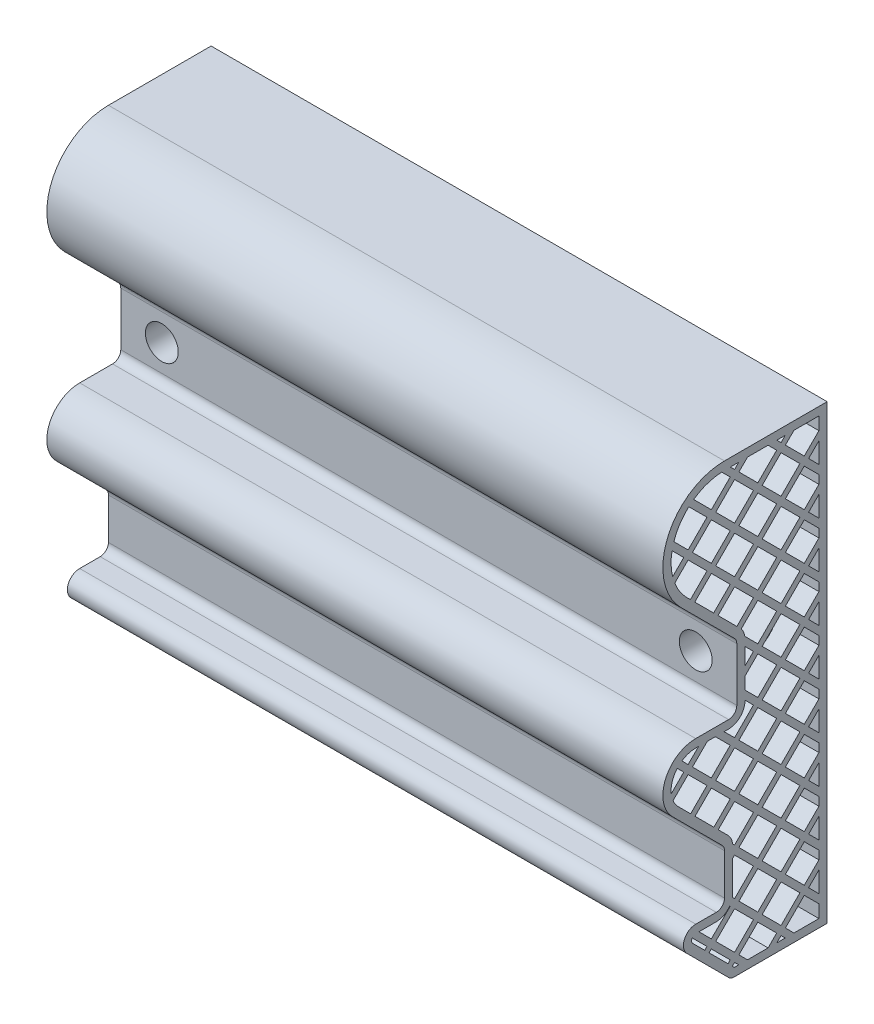
from build123d import *

# Parameters (mm, degrees)
SALIENTE_EXTRUIR1_DEPTH = 150
CORTAR_EXTRUIR3_DEPTH   = 1
CORTAR_EXTRUIR4_DEPTH   = 150
CROQUIS2_R              = 4
CORTAR_EXTRUIR1_DEPTH   = 23
CROQUIS7_R              = 5.5
CROQUIS7_R_2            = 4
SALIENTE_EXTRUIR2_DEPTH = 22
SALIENTE_EXTRUIR4_DEPTH = 1
CORTAR_EXTRUIR9_DEPTH   = 1


with BuildPart() as part:
    # Croquis1 → Saliente-Extruir1 (new body)
    with BuildSketch(Plane(origin=(0, 0, 0), x_dir=(0, 0, -1), z_dir=(1, 0, 0))):
        with BuildLine():
            Line((0, 0), (-22.597979746, 0))
            ThreePointArc((-22.597979746, 0), (-23.363346611, 0.152240935), (-24.012193309, 0.585786438))
            Line((-24.012193309, 0.585786438), (-34.121320344, 10.694913472))
            ThreePointArc((-34.121320344, 10.694913472), (-34.771638598, 13.964284113), (-32, 15.816233816))
            Line((-32, 15.816233816), (-27, 15.816233816))
            ThreePointArc((-27, 15.816233816), (-25.585786438, 16.402020254), (-25, 17.816233816))
            Line((-25, 17.816233816), (-25, 27.816233816))
            ThreePointArc((-25, 27.816233816), (-25.152240935, 28.581600681), (-25.585786438, 29.230447378))
            Line((-25.585786438, 29.230447378), (-37.656854249, 41.30151519))
            ThreePointArc((-37.656854249, 41.30151519), (-39.39103626, 50.019836899), (-32, 54.95836944))
            Line((-32, 54.95836944), (-24, 54.95836944))
            ThreePointArc((-24, 54.95836944), (-22.585786438, 55.544155877), (-22, 56.95836944))
            Line((-22, 56.95836944), (-22, 69.95836944))
            ThreePointArc((-22, 69.95836944), (-22.152240935, 70.723736304), (-22.585786438, 71.372583002))
            Line((-22.585786438, 71.372583002), (-35.606601718, 84.393398282))
            ThreePointArc((-35.606601718, 84.393398282), (-38.858192988, 100.740251485), (-25, 110))
            Line((-25, 110), (0, 110))
            Line((0, 110), (0, 0))
        make_face()
    extrude(amount=SALIENTE_EXTRUIR1_DEPTH)

    # Croquis3 → Cortar-Extruir3 (cut)
    with BuildSketch(Plane(origin=(150, 0, 0), x_dir=(0, 0, -1), z_dir=(1, 0, 0))):
        with BuildLine():
            Line((-24, 52.95836944), (-32, 52.95836944))
            ThreePointArc((-32, 52.95836944), (-37.543277195, 49.254470034), (-36.242640687, 42.715728753))
            Line((-36.242640687, 42.715728753), (-24.171572875, 30.644660941))
            ThreePointArc((-24.171572875, 30.644660941), (-23.30448187, 29.346967545), (-23, 27.816233816))
            Line((-23, 27.816233816), (-23, 17.816233816))
            ThreePointArc((-23, 17.816233816), (-24.171572875, 14.987806691), (-27, 13.816233816))
            Line((-27, 13.816233816), (-32, 13.816233816))
            ThreePointArc((-32, 13.816233816), (-32.923879533, 13.198917248), (-32.707106781, 12.109127035))
            Line((-32.707106781, 12.109127035), (-22.597979746, 2))
            Line((-22.597979746, 2), (-2, 2))
            Line((-2, 2), (-2, 108))
            Line((-2, 108), (-25, 108))
            ThreePointArc((-25, 108), (-37.010433923, 99.974884621), (-34.192388155, 85.807611845))
            Line((-34.192388155, 85.807611845), (-21.171572875, 72.786796564))
            ThreePointArc((-21.171572875, 72.786796564), (-20.30448187, 71.489103169), (-20, 69.95836944))
            Line((-20, 69.95836944), (-20, 56.95836944))
            ThreePointArc((-20, 56.95836944), (-21.171572875, 54.129942315), (-24, 52.95836944))
        make_face()
    extrude(amount=-CORTAR_EXTRUIR3_DEPTH, mode=Mode.SUBTRACT)

    # Croquis6 → Cortar-Extruir4 (cut)
    with BuildSketch(Plane(origin=(150, 0, 0), x_dir=(0, 0, -1), z_dir=(1, 0, 0))):
        Polygon((-22.539105243, 106.972348417), (-21.511453661, 108), (-23.566756826, 108), align=None)
        with BuildLine():
            Line((-25.670761009, 107.982683839), (-23.599765415, 105.911688245))
            Line((-23.599765415, 105.911688245), (-28.195959493, 101.315494168))
            Line((-28.195959493, 101.315494168), (-32.499323448, 105.618858123))
            ThreePointArc((-32.499323448, 105.618858123), (-29.252586038, 107.284767478), (-25.670761009, 107.982683839))
        make_face()
        Polygon((-22.597979746, 2), (-21.511453661, 2), (-22.539105243, 3.027651583), (-23.082368286, 2.48438854), align=None)
        Polygon((-2, 2), (-2, 5.115963337), (-5.568542495, 8.684505832), (-10.164736573, 4.088311755), (-8.076424818, 2), align=None)
        Polygon((-2, 108), (-8.076424818, 108), (-10.164736573, 105.911688245), (-5.568542495, 101.315494168), (-2, 104.884036663), align=None)
        with BuildLine():
            Line((-34.192388155, 85.807611845), (-33.291260736, 84.906484425))
            Line((-33.291260736, 84.906484425), (-29.256619665, 88.941125497))
            Line((-29.256619665, 88.941125497), (-33.852813742, 93.537319575))
            Line((-33.852813742, 93.537319575), (-37.112101908, 90.278031409))
            ThreePointArc((-37.112101908, 90.278031409), (-35.884231116, 87.891307222), (-34.192388155, 85.807611845))
        make_face()
        Polygon((-20, 68.370797333), (-20, 64.256619665), (-17.942911166, 66.313708499), align=None)
        with BuildLine():
            Line((-24, 52.95836944), (-25.093668761, 52.95836944))
            Line((-25.093668761, 52.95836944), (-22.539105243, 50.403805922))
            Line((-22.539105243, 50.403805922), (-17.942911166, 55))
            Line((-17.942911166, 55), (-20, 57.057088834))
            Line((-20, 57.057088834), (-20, 56.95836944))
            ThreePointArc((-20, 56.95836944), (-21.171572875, 54.129942315), (-24, 52.95836944))
        make_face()
        with BuildLine():
            Line((-36.242640687, 42.715728753), (-33.23491155, 39.707999616))
            Line((-33.23491155, 39.707999616), (-29.256619665, 43.686291501))
            Line((-29.256619665, 43.686291501), (-33.852813742, 48.282485579))
            Line((-33.852813742, 48.282485579), (-37.522518719, 44.612780602))
            ThreePointArc((-37.522518719, 44.612780602), (-36.97386027, 43.602670703), (-36.242640687, 42.715728753))
        make_face()
        with BuildLine():
            Line((-23, 25.194173824), (-23, 17.816233816))
            ThreePointArc((-23, 17.816233816), (-23.020762528, 17.409209069), (-23.082834572, 17.006409754))
            Line((-23.082834572, 17.006409754), (-22.539105243, 16.462680425))
            Line((-22.539105243, 16.462680425), (-17.942911166, 21.058874503))
            Line((-17.942911166, 21.058874503), (-22.539105243, 25.655068581))
            Line((-22.539105243, 25.655068581), (-23, 25.194173824))
        make_face()
        with BuildLine():
            Line((-27, 13.816233816), (-31.206367133, 13.816233816))
            Line((-31.206367133, 13.816233816), (-28.195959493, 10.805826176))
            Line((-28.195959493, 10.805826176), (-23.599765415, 15.402020254))
            Line((-23.599765415, 15.402020254), (-23.721861011, 15.52411585))
            ThreePointArc((-23.721861011, 15.52411585), (-25.151821419, 14.268807152), (-27, 13.816233816))
        make_face()
        with BuildLine():
            Line((-32.707106781, 12.109127035), (-29.799882708, 9.201902961))
            Line((-29.799882708, 9.201902961), (-29.256619665, 9.745166004))
            Line((-29.256619665, 9.745166004), (-32.851706537, 13.340252876))
            ThreePointArc((-32.851706537, 13.340252876), (-32.99317292, 12.699582409), (-32.707106781, 12.109127035))
        make_face()
        with BuildLine():
            Line((-37.622305649, 91.889148011), (-34.913473914, 94.597979746))
            Line((-34.913473914, 94.597979746), (-37.766797289, 97.451303121))
            ThreePointArc((-37.766797289, 97.451303121), (-37.995615775, 94.662404627), (-37.622305649, 91.889148011))
        make_face()
        with BuildLine():
            Line((-37.325931232, 99.131757407), (-33.852813742, 95.658639918))
            Line((-33.852813742, 95.658639918), (-29.256619665, 100.254833996))
            Line((-29.256619665, 100.254833996), (-33.679721302, 104.677935633))
            ThreePointArc((-33.679721302, 104.677935633), (-35.862752083, 102.14147164), (-37.325931232, 99.131757407))
        make_face()
        Polygon((-11.225396744, 106.972348417), (-10.197745162, 108), (-12.253048327, 108), align=None)
        Polygon((-4.507882323, 100.254833996), (-2, 97.746951673), (-2, 102.762716319), align=None)
        Polygon((-14.374368671, 108), (-12.286056916, 105.911688245), (-16.882250994, 101.315494168), (-21.478445072, 105.911688245), (-19.390133317, 108), align=None)
        Polygon((-27.578057301, 34.051145366), (-23.599765415, 38.029437252), (-28.195959493, 42.625631329), (-32.174251378, 38.647339444), align=None)
        with BuildLine():
            Line((-37.96305573, 46.293563935), (-34.913473914, 49.343145751))
            Line((-34.913473914, 49.343145751), (-36.498746009, 50.928417846))
            ThreePointArc((-36.498746009, 50.928417846), (-37.721257869, 48.765911527), (-37.96305573, 46.293563935))
        make_face()
        with BuildLine():
            Line((-35.370928508, 51.921920688), (-33.852813742, 50.403805922))
            Line((-33.852813742, 50.403805922), (-31.298250225, 52.95836944))
            Line((-31.298250225, 52.95836944), (-32, 52.95836944))
            ThreePointArc((-32, 52.95836944), (-33.763333847, 52.693406819), (-35.370928508, 51.921920688))
        make_face()
        Polygon((-32.792153571, 49.343145751), (-28.195959493, 44.746951673), (-23.599765415, 49.343145751), (-27.214989104, 52.95836944), (-29.176929881, 52.95836944), align=None)
        Polygon((-20, 59.178409178), (-16.882250994, 56.060660172), (-12.286056916, 60.656854249), (-16.882250994, 65.253048327), (-20, 62.135299321), align=None)
        with BuildLine():
            Line((-16.882250994, 67.374368671), (-12.286056916, 71.970562748))
            Line((-12.286056916, 71.970562748), (-16.882250994, 76.566756826))
            Line((-16.882250994, 76.566756826), (-20.928381547, 72.520626273))
            ThreePointArc((-20.928381547, 72.520626273), (-20.347292714, 71.588623861), (-20.04159352, 70.533711197))
            Line((-20.04159352, 70.533711197), (-16.882250994, 67.374368671))
        make_face()
        Polygon((-21.977552237, 73.592775926), (-17.942911166, 77.627416998), (-22.539105243, 82.223611076), (-26.573746315, 78.188970004), align=None)
        Polygon((-27.634406487, 79.249630176), (-23.599765415, 83.284271247), (-28.195959493, 87.880465325), (-32.230600564, 83.845824254), align=None)
        Polygon((-4.507882323, 77.627416998), (-2, 80.135299321), (-2, 75.119534675), align=None)
        Polygon((-5.568542495, 76.566756826), (-2, 72.998214331), (-2, 70.942911166), (-5.568542495, 67.374368671), (-10.164736573, 71.970562748), align=None)
        Polygon((-4.507882323, 66.313708499), (-2, 68.821590822), (-2, 63.805826176), align=None)
        Polygon((-5.568542495, 65.253048327), (-2, 61.684505832), (-2, 59.629202667), (-5.568542495, 56.060660172), (-10.164736573, 60.656854249), align=None)
        Polygon((-4.507882323, 55), (-2, 57.507882323), (-2, 52.492117677), align=None)
        Polygon((-5.568542495, 53.939339828), (-2, 50.370797333), (-2, 48.315494168), (-5.568542495, 44.746951673), (-10.164736573, 49.343145751), align=None)
        Polygon((-4.507882323, 43.686291501), (-2, 46.194173824), (-2, 41.178409178), align=None)
        Polygon((-5.568542495, 42.625631329), (-2, 39.057088834), (-2, 37.001785669), (-5.568542495, 33.433243174), (-10.164736573, 38.029437252), align=None)
        Polygon((-4.507882323, 32.372583002), (-2, 34.880465325), (-2, 29.864700679), align=None)
        Polygon((-5.568542495, 31.31192283), (-2, 27.743380335), (-2, 25.68807717), (-5.568542495, 22.119534675), (-10.164736573, 26.715728753), align=None)
        Polygon((-4.507882323, 21.058874503), (-2, 23.566756826), (-2, 18.55099218), align=None)
        Polygon((-5.568542495, 19.998214331), (-2, 16.429671836), (-2, 14.374368671), (-5.568542495, 10.805826176), (-10.164736573, 15.402020254), align=None)
        Polygon((-4.507882323, 9.745166004), (-2, 12.253048327), (-2, 7.237283681), align=None)
        Polygon((-11.225396744, 3.027651583), (-10.197745162, 2), (-12.253048327, 2), align=None)
        Polygon((-14.374368671, 2), (-12.286056916, 4.088311755), (-16.882250994, 8.684505832), (-21.478445072, 4.088311755), (-19.390133317, 2), align=None)
        Polygon((-24.143028458, 3.545048712), (-23.599765415, 4.088311755), (-28.195959493, 8.684505832), (-28.739222536, 8.141242789), align=None)
        with BuildLine():
            Line((-23.02494127, 28.262224951), (-22.539105243, 27.776388924))
            Line((-22.539105243, 27.776388924), (-17.942911166, 32.372583002))
            Line((-17.942911166, 32.372583002), (-22.539105243, 36.96877708))
            Line((-22.539105243, 36.96877708), (-26.517397129, 32.990485194))
            Line((-26.517397129, 32.990485194), (-24.171572875, 30.644660941))
            ThreePointArc((-24.171572875, 30.644660941), (-23.395717096, 29.550922475), (-23.02494127, 28.262224951))
        make_face()
        Polygon((-5.568542495, 99.194173824), (-2, 95.625631329), (-2, 93.570328164), (-5.568542495, 90.001785669), (-10.164736573, 94.597979746), align=None)
        Polygon((-4.507882323, 88.941125497), (-2, 91.44900782), (-2, 86.433243174), align=None)
        Polygon((-5.568542495, 87.880465325), (-2, 84.31192283), (-2, 82.256619665), (-5.568542495, 78.68807717), (-10.164736573, 83.284271247), align=None)
        Polygon((-21.478445072, 38.029437252), (-16.882250994, 42.625631329), (-12.286056916, 38.029437252), (-16.882250994, 33.433243174), align=None)
        Polygon((-27.135299321, 43.686291501), (-22.539105243, 39.090097423), (-17.942911166, 43.686291501), (-22.539105243, 48.282485579), align=None)
        Polygon((-21.478445072, 49.343145751), (-16.882250994, 44.746951673), (-12.286056916, 49.343145751), (-16.882250994, 53.939339828), align=None)
        Polygon((-15.821590822, 55), (-11.225396744, 50.403805922), (-6.629202667, 55), (-11.225396744, 59.596194078), align=None)
        Polygon((-15.821590822, 66.313708499), (-11.225396744, 61.717514421), (-6.629202667, 66.313708499), (-11.225396744, 70.909902577), align=None)
        Polygon((-15.821590822, 77.627416998), (-11.225396744, 73.03122292), (-6.629202667, 77.627416998), (-11.225396744, 82.223611076), align=None)
        Polygon((-16.882250994, 78.68807717), (-12.286056916, 83.284271247), (-16.882250994, 87.880465325), (-21.478445072, 83.284271247), align=None)
        Polygon((-15.821590822, 88.941125497), (-11.225396744, 84.344931419), (-6.629202667, 88.941125497), (-11.225396744, 93.537319575), align=None)
        Polygon((-11.225396744, 95.658639918), (-6.629202667, 100.254833996), (-11.225396744, 104.851028074), (-15.821590822, 100.254833996), align=None)
        Polygon((-21.478445072, 94.597979746), (-16.882250994, 99.194173824), (-12.286056916, 94.597979746), (-16.882250994, 90.001785669), align=None)
        Polygon((-22.539105243, 84.344931419), (-17.942911166, 88.941125497), (-22.539105243, 93.537319575), (-27.135299321, 88.941125497), align=None)
        Polygon((-32.792153571, 94.597979746), (-28.195959493, 90.001785669), (-23.599765415, 94.597979746), (-28.195959493, 99.194173824), align=None)
        Polygon((-22.539105243, 95.658639918), (-17.942911166, 100.254833996), (-22.539105243, 104.851028074), (-27.135299321, 100.254833996), align=None)
        Polygon((-15.821590822, 43.686291501), (-11.225396744, 39.090097423), (-6.629202667, 43.686291501), (-11.225396744, 48.282485579), align=None)
        Polygon((-11.225396744, 27.776388924), (-6.629202667, 32.372583002), (-11.225396744, 36.96877708), (-15.821590822, 32.372583002), align=None)
        Polygon((-16.882250994, 22.119534675), (-12.286056916, 26.715728753), (-16.882250994, 31.31192283), (-21.478445072, 26.715728753), align=None)
        Polygon((-15.821590822, 9.745166004), (-11.225396744, 5.148971926), (-6.629202667, 9.745166004), (-11.225396744, 14.341360082), align=None)
        Polygon((-16.882250994, 10.805826176), (-12.286056916, 15.402020254), (-16.882250994, 19.998214331), (-21.478445072, 15.402020254), align=None)
        Polygon((-11.225396744, 16.462680425), (-6.629202667, 21.058874503), (-11.225396744, 25.655068581), (-15.821590822, 21.058874503), align=None)
        Polygon((-27.135299321, 9.745166004), (-22.539105243, 5.148971926), (-17.942911166, 9.745166004), (-22.539105243, 14.341360082), align=None)
    extrude(amount=-CORTAR_EXTRUIR4_DEPTH, mode=Mode.SUBTRACT)

    # Croquis2 → Cortar-Extruir1 (cut, through all)
    with BuildSketch(Plane.XY.offset(22)):
        with Locations((10, 63.45836944)):
            Circle(CROQUIS2_R)
        with Locations((140, 63.45836944)):
            Circle(CROQUIS2_R)
    extrude(amount=-CORTAR_EXTRUIR1_DEPTH, mode=Mode.SUBTRACT)

    # Croquis7 → Saliente-Extruir2 (add)
    with BuildSketch(Plane.XY.offset(22)):
        with Locations((10, 63.45836944)):
            Circle(CROQUIS7_R)
        with Locations((10, 63.45836944)):
            Circle(CROQUIS7_R_2, mode=Mode.SUBTRACT)
        with Locations((140, 63.45836944)):
            Circle(CROQUIS7_R)
        with Locations((140, 63.45836944)):
            Circle(CROQUIS7_R_2, mode=Mode.SUBTRACT)
    extrude(amount=-SALIENTE_EXTRUIR2_DEPTH)

    # Croquis10 → Saliente-Extruir4 (add)
    with BuildSketch(Plane(origin=(150, 0, 0), x_dir=(0, 0, -1), z_dir=(1, 0, 0))):
        with BuildLine():
            Line((-24, 54.95836944), (-32, 54.95836944))
            ThreePointArc((-32, 54.95836944), (-39.39103626, 50.019836899), (-37.656854249, 41.30151519))
            Line((-37.656854249, 41.30151519), (-25.585786438, 29.230447378))
            ThreePointArc((-25.585786438, 29.230447378), (-25.152240935, 28.581600681), (-25, 27.816233816))
            Line((-25, 27.816233816), (-25, 17.816233816))
            ThreePointArc((-25, 17.816233816), (-25.585786438, 16.402020254), (-27, 15.816233816))
            Line((-27, 15.816233816), (-32, 15.816233816))
            ThreePointArc((-32, 15.816233816), (-34.771638598, 13.964284113), (-34.121320344, 10.694913472))
            Line((-34.121320344, 10.694913472), (-24.012193309, 0.585786438))
            ThreePointArc((-24.012193309, 0.585786438), (-23.363346611, 0.152240935), (-22.597979746, 0))
            Line((-22.597979746, 0), (0, 0))
            Line((0, 0), (0, 110))
            Line((0, 110), (-25, 110))
            ThreePointArc((-25, 110), (-38.858192988, 100.740251485), (-35.606601718, 84.393398282))
            Line((-35.606601718, 84.393398282), (-22.585786438, 71.372583002))
            ThreePointArc((-22.585786438, 71.372583002), (-22.152240935, 70.723736304), (-22, 69.95836944))
            Line((-22, 69.95836944), (-22, 56.95836944))
            ThreePointArc((-22, 56.95836944), (-22.585786438, 55.544155877), (-24, 54.95836944))
        make_face()
    extrude(amount=-SALIENTE_EXTRUIR4_DEPTH)

    # Croquis11 → Cortar-Extruir9 (cut)
    with BuildSketch(Plane(origin=(150, 0, 0), x_dir=(0, 0, -1), z_dir=(1, 0, 0))):
        Polygon((-27.135299321, 9.745166004), (-22.539105243, 5.148971926), (-17.942911166, 9.745166004), (-22.539105243, 14.341360082), align=None)
        Polygon((-11.225396744, 16.462680425), (-6.629202667, 21.058874503), (-11.225396744, 25.655068581), (-15.821590822, 21.058874503), align=None)
        Polygon((-22.539105243, 106.972348417), (-21.511453661, 108), (-23.566756826, 108), align=None)
        with BuildLine():
            Line((-32.499323448, 105.618858123), (-28.195959493, 101.315494168))
            Line((-28.195959493, 101.315494168), (-23.599765415, 105.911688245))
            Line((-23.599765415, 105.911688245), (-25.670761009, 107.982683839))
            ThreePointArc((-25.670761009, 107.982683839), (-29.252586038, 107.284767478), (-32.499323448, 105.618858123))
        make_face()
        Polygon((-11.225396744, 106.972348417), (-10.197745162, 108), (-12.253048327, 108), align=None)
        with BuildLine():
            Line((-37.325931232, 99.131757407), (-33.852813742, 95.658639918))
            Line((-33.852813742, 95.658639918), (-29.256619665, 100.254833996))
            Line((-29.256619665, 100.254833996), (-33.679721302, 104.677935633))
            ThreePointArc((-33.679721302, 104.677935633), (-35.862752083, 102.14147164), (-37.325931232, 99.131757407))
        make_face()
        with BuildLine():
            Line((-34.913473914, 94.597979746), (-37.766797289, 97.451303121))
            ThreePointArc((-37.766797289, 97.451303121), (-37.995615775, 94.662404627), (-37.622305649, 91.889148011))
            Line((-37.622305649, 91.889148011), (-34.913473914, 94.597979746))
        make_face()
        with BuildLine():
            Line((-33.291260736, 84.906484425), (-29.256619665, 88.941125497))
            Line((-29.256619665, 88.941125497), (-33.852813742, 93.537319575))
            Line((-33.852813742, 93.537319575), (-37.112101908, 90.278031409))
            ThreePointArc((-37.112101908, 90.278031409), (-35.884231116, 87.891307222), (-34.192388155, 85.807611845))
            Line((-34.192388155, 85.807611845), (-33.291260736, 84.906484425))
        make_face()
        Polygon((-27.578057301, 34.051145366), (-23.599765415, 38.029437252), (-28.195959493, 42.625631329), (-32.174251378, 38.647339444), align=None)
        Polygon((-12.286056916, 105.911688245), (-14.374368671, 108), (-19.390133317, 108), (-21.478445072, 105.911688245), (-16.882250994, 101.315494168), align=None)
        Polygon((-2, 97.746951673), (-2, 102.762716319), (-4.507882323, 100.254833996), align=None)
        Polygon((-8.076424818, 108), (-10.164736573, 105.911688245), (-5.568542495, 101.315494168), (-2, 104.884036663), (-2, 108), align=None)
        Polygon((-32.792153571, 49.343145751), (-28.195959493, 44.746951673), (-23.599765415, 49.343145751), (-27.214989104, 52.95836944), (-29.176929881, 52.95836944), align=None)
        with BuildLine():
            Line((-35.370928508, 51.921920688), (-33.852813742, 50.403805922))
            Line((-33.852813742, 50.403805922), (-31.298250225, 52.95836944))
            Line((-31.298250225, 52.95836944), (-32, 52.95836944))
            ThreePointArc((-32, 52.95836944), (-33.763333847, 52.693406819), (-35.370928508, 51.921920688))
        make_face()
        with BuildLine():
            Line((-37.96305573, 46.293563935), (-34.913473914, 49.343145751))
            Line((-34.913473914, 49.343145751), (-36.498746009, 50.928417846))
            ThreePointArc((-36.498746009, 50.928417846), (-37.721257869, 48.765911527), (-37.96305573, 46.293563935))
        make_face()
        with BuildLine():
            Line((-36.242640687, 42.715728753), (-33.23491155, 39.707999616))
            Line((-33.23491155, 39.707999616), (-29.256619665, 43.686291501))
            Line((-29.256619665, 43.686291501), (-33.852813742, 48.282485579))
            Line((-33.852813742, 48.282485579), (-37.522518719, 44.612780602))
            ThreePointArc((-37.522518719, 44.612780602), (-36.97386027, 43.602670703), (-36.242640687, 42.715728753))
        make_face()
        with BuildLine():
            Line((-25.093668761, 52.95836944), (-22.539105243, 50.403805922))
            Line((-22.539105243, 50.403805922), (-17.942911166, 55))
            Line((-17.942911166, 55), (-20, 57.057088834))
            Line((-20, 57.057088834), (-20, 56.95836944))
            ThreePointArc((-20, 56.95836944), (-21.171572875, 54.129942315), (-24, 52.95836944))
            Line((-24, 52.95836944), (-25.093668761, 52.95836944))
        make_face()
        with BuildLine():
            Line((-16.882250994, 67.374368671), (-12.286056916, 71.970562748))
            Line((-12.286056916, 71.970562748), (-16.882250994, 76.566756826))
            Line((-16.882250994, 76.566756826), (-20.928381547, 72.520626273))
            ThreePointArc((-20.928381547, 72.520626273), (-20.347292714, 71.588623861), (-20.04159352, 70.533711197))
            Line((-20.04159352, 70.533711197), (-16.882250994, 67.374368671))
        make_face()
        Polygon((-20, 59.178409178), (-16.882250994, 56.060660172), (-12.286056916, 60.656854249), (-16.882250994, 65.253048327), (-20, 62.135299321), align=None)
        Polygon((-20, 68.370797333), (-20, 64.256619665), (-17.942911166, 66.313708499), align=None)
        Polygon((-2, 72.998214331), (-5.568542495, 76.566756826), (-10.164736573, 71.970562748), (-5.568542495, 67.374368671), (-2, 70.942911166), align=None)
        Polygon((-2, 80.135299321), (-4.507882323, 77.627416998), (-2, 75.119534675), align=None)
        Polygon((-27.634406487, 79.249630176), (-23.599765415, 83.284271247), (-28.195959493, 87.880465325), (-32.230600564, 83.845824254), align=None)
        Polygon((-22.539105243, 82.223611076), (-26.573746315, 78.188970004), (-21.977552237, 73.592775926), (-17.942911166, 77.627416998), align=None)
        Polygon((-2, 50.370797333), (-5.568542495, 53.939339828), (-10.164736573, 49.343145751), (-5.568542495, 44.746951673), (-2, 48.315494168), align=None)
        Polygon((-2, 57.507882323), (-4.507882323, 55), (-2, 52.492117677), align=None)
        Polygon((-2, 61.684505832), (-5.568542495, 65.253048327), (-10.164736573, 60.656854249), (-5.568542495, 56.060660172), (-2, 59.629202667), align=None)
        Polygon((-2, 63.805826176), (-2, 68.821590822), (-4.507882323, 66.313708499), align=None)
        Polygon((-2, 27.743380335), (-5.568542495, 31.31192283), (-10.164736573, 26.715728753), (-5.568542495, 22.119534675), (-2, 25.68807717), align=None)
        Polygon((-2, 34.880465325), (-4.507882323, 32.372583002), (-2, 29.864700679), align=None)
        Polygon((-2, 39.057088834), (-5.568542495, 42.625631329), (-10.164736573, 38.029437252), (-5.568542495, 33.433243174), (-2, 37.001785669), align=None)
        Polygon((-2, 41.178409178), (-2, 46.194173824), (-4.507882323, 43.686291501), align=None)
        Polygon((-10.197745162, 2), (-11.225396744, 3.027651583), (-12.253048327, 2), align=None)
        Polygon((-2, 12.253048327), (-4.507882323, 9.745166004), (-2, 7.237283681), align=None)
        Polygon((-2, 16.429671836), (-5.568542495, 19.998214331), (-10.164736573, 15.402020254), (-5.568542495, 10.805826176), (-2, 14.374368671), align=None)
        Polygon((-2, 18.55099218), (-2, 23.566756826), (-4.507882323, 21.058874503), align=None)
        Polygon((-2, 5.115963337), (-5.568542495, 8.684505832), (-10.164736573, 4.088311755), (-8.076424818, 2), (-2, 2), align=None)
        Polygon((-24.143028458, 3.545048712), (-23.599765415, 4.088311755), (-28.195959493, 8.684505832), (-28.739222536, 8.141242789), align=None)
        Polygon((-12.286056916, 4.088311755), (-16.882250994, 8.684505832), (-21.478445072, 4.088311755), (-19.390133317, 2), (-14.374368671, 2), align=None)
        with BuildLine():
            Line((-29.799882708, 9.201902961), (-29.256619665, 9.745166004))
            Line((-29.256619665, 9.745166004), (-32.851706537, 13.340252876))
            ThreePointArc((-32.851706537, 13.340252876), (-32.99317292, 12.699582409), (-32.707106781, 12.109127035))
            Line((-32.707106781, 12.109127035), (-29.799882708, 9.201902961))
        make_face()
        Polygon((-21.511453661, 2), (-22.539105243, 3.027651583), (-23.082368286, 2.48438854), (-22.597979746, 2), align=None)
        with BuildLine():
            Line((-23.02494127, 28.262224951), (-22.539105243, 27.776388924))
            Line((-22.539105243, 27.776388924), (-17.942911166, 32.372583002))
            Line((-17.942911166, 32.372583002), (-22.539105243, 36.96877708))
            Line((-22.539105243, 36.96877708), (-26.517397129, 32.990485194))
            Line((-26.517397129, 32.990485194), (-24.171572875, 30.644660941))
            ThreePointArc((-24.171572875, 30.644660941), (-23.395717096, 29.550922475), (-23.02494127, 28.262224951))
        make_face()
        with BuildLine():
            Line((-23.599765415, 15.402020254), (-23.721861011, 15.52411585))
            ThreePointArc((-23.721861011, 15.52411585), (-25.151821419, 14.268807152), (-27, 13.816233816))
            Line((-27, 13.816233816), (-31.206367133, 13.816233816))
            Line((-31.206367133, 13.816233816), (-28.195959493, 10.805826176))
            Line((-28.195959493, 10.805826176), (-23.599765415, 15.402020254))
        make_face()
        with BuildLine():
            Line((-22.539105243, 25.655068581), (-23, 25.194173824))
            Line((-23, 25.194173824), (-23, 17.816233816))
            ThreePointArc((-23, 17.816233816), (-23.020762528, 17.409209069), (-23.082834572, 17.006409754))
            Line((-23.082834572, 17.006409754), (-22.539105243, 16.462680425))
            Line((-22.539105243, 16.462680425), (-17.942911166, 21.058874503))
            Line((-17.942911166, 21.058874503), (-22.539105243, 25.655068581))
        make_face()
        Polygon((-27.135299321, 43.686291501), (-22.539105243, 39.090097423), (-17.942911166, 43.686291501), (-22.539105243, 48.282485579), align=None)
        Polygon((-2, 84.31192283), (-5.568542495, 87.880465325), (-10.164736573, 83.284271247), (-5.568542495, 78.68807717), (-2, 82.256619665), align=None)
        Polygon((-2, 91.44900782), (-4.507882323, 88.941125497), (-2, 86.433243174), align=None)
        Polygon((-5.568542495, 90.001785669), (-2, 93.570328164), (-2, 95.625631329), (-5.568542495, 99.194173824), (-10.164736573, 94.597979746), align=None)
        Polygon((-15.821590822, 77.627416998), (-11.225396744, 73.03122292), (-6.629202667, 77.627416998), (-11.225396744, 82.223611076), align=None)
        Polygon((-15.821590822, 66.313708499), (-11.225396744, 61.717514421), (-6.629202667, 66.313708499), (-11.225396744, 70.909902577), align=None)
        Polygon((-15.821590822, 55), (-11.225396744, 50.403805922), (-6.629202667, 55), (-11.225396744, 59.596194078), align=None)
        Polygon((-16.882250994, 99.194173824), (-21.478445072, 94.597979746), (-16.882250994, 90.001785669), (-12.286056916, 94.597979746), align=None)
        Polygon((-11.225396744, 95.658639918), (-6.629202667, 100.254833996), (-11.225396744, 104.851028074), (-15.821590822, 100.254833996), align=None)
        Polygon((-15.821590822, 88.941125497), (-11.225396744, 84.344931419), (-6.629202667, 88.941125497), (-11.225396744, 93.537319575), align=None)
        Polygon((-16.882250994, 78.68807717), (-12.286056916, 83.284271247), (-16.882250994, 87.880465325), (-21.478445072, 83.284271247), align=None)
        Polygon((-22.539105243, 95.658639918), (-17.942911166, 100.254833996), (-22.539105243, 104.851028074), (-27.135299321, 100.254833996), align=None)
        Polygon((-32.792153571, 94.597979746), (-28.195959493, 90.001785669), (-23.599765415, 94.597979746), (-28.195959493, 99.194173824), align=None)
        Polygon((-22.539105243, 84.344931419), (-17.942911166, 88.941125497), (-22.539105243, 93.537319575), (-27.135299321, 88.941125497), align=None)
        Polygon((-16.882250994, 44.746951673), (-12.286056916, 49.343145751), (-16.882250994, 53.939339828), (-21.478445072, 49.343145751), align=None)
        Polygon((-12.286056916, 38.029437252), (-16.882250994, 42.625631329), (-21.478445072, 38.029437252), (-16.882250994, 33.433243174), align=None)
        Polygon((-16.882250994, 10.805826176), (-12.286056916, 15.402020254), (-16.882250994, 19.998214331), (-21.478445072, 15.402020254), align=None)
        Polygon((-15.821590822, 9.745166004), (-11.225396744, 5.148971926), (-6.629202667, 9.745166004), (-11.225396744, 14.341360082), align=None)
        Polygon((-11.225396744, 39.090097423), (-6.629202667, 43.686291501), (-11.225396744, 48.282485579), (-15.821590822, 43.686291501), align=None)
        Polygon((-16.882250994, 22.119534675), (-12.286056916, 26.715728753), (-16.882250994, 31.31192283), (-21.478445072, 26.715728753), align=None)
        Polygon((-11.225396744, 27.776388924), (-6.629202667, 32.372583002), (-11.225396744, 36.96877708), (-15.821590822, 32.372583002), align=None)
    extrude(amount=-CORTAR_EXTRUIR9_DEPTH, mode=Mode.SUBTRACT)


solid = part.part
